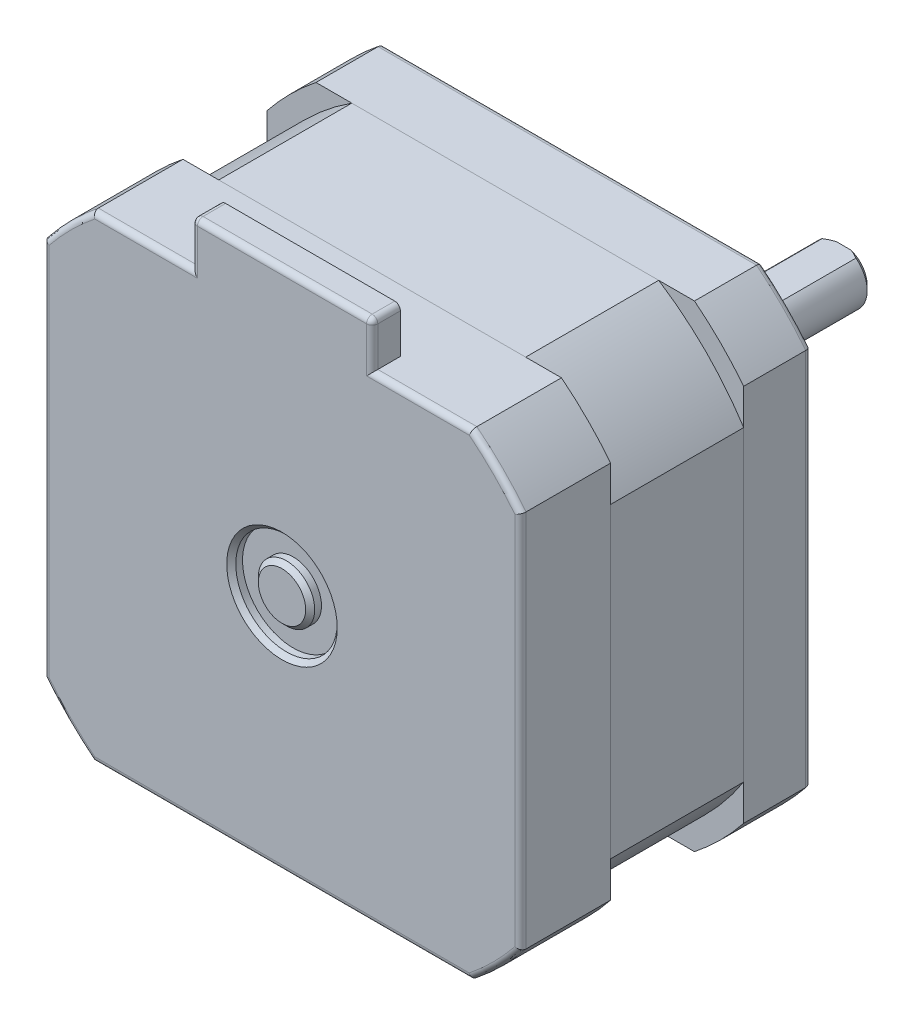
from build123d import *

# Parameters (mm, degrees)
BOSS_EXTRU_1_DEPTH           = 6
BOSS_EXTRU_2_DEPTH           = 11.8
BOSS_EXTRU_3_DEPTH           = 8
ESQUISSE4_W                  = 16
ESQUISSE4_H                  = 2.5
BOSS_EXTRU_4_DEPTH           = 4
ESQUISSE5_W                  = 2
ESQUISSE5_H                  = 6.5
ESQUISSE5_W_2                = 24
ESQUISSE5_H_2                = 2.5
CONG_1_R                     = 0.5
CONG_2_R                     = 0.5
CHANFREIN1_SIZE              = 0.4
CHANFREIN2_SIZE              = 0.4
ESQUISSE6_W                  = 15
ESQUISSE6_H                  = 0.5
ENL_V_MAT_EXTRU_1_DEPTH      = 22.1500001
ENL_V_MAT_EXTRU_1_DEPTH_BACK = 22.1500001
ESQUISSE7_R                  = 4.5
ESQUISSE7_R_2                = 2.5
ENL_V_MAT_EXTRU_2_DEPTH      = 1
CHANFREIN3_SIZE              = 0.4
TROU_TARAUD_M31_AT_2_COUNT   = 2
TROU_TARAUD_M31_AT_2_PITCH   = 31
TROU_TARAUD_M31_AT_3_COUNT   = 2
TROU_TARAUD_M31_AT_3_PITCH   = 43.840620434
TROU_TARAUD_M31_AT_4_COUNT   = 2
TROU_TARAUD_M31_AT_4_PITCH   = 31


with BuildPart() as part:
    # Esquisse1 → Boss.-Extru.1 (new body)
    with BuildSketch(Plane.XY):
        with BuildLine():
            Line((21.15, 16.783250579), (21.15, -16.783250579))
            ThreePointArc((21.15, -16.783250579), (19.091883092, -19.091883092), (16.783250579, -21.15))
            Line((16.783250579, -21.15), (-16.783250579, -21.15))
            ThreePointArc((-16.783250579, -21.15), (-19.091883092, -19.091883092), (-21.15, -16.783250579))
            Line((-21.15, -16.783250579), (-21.15, 16.783250579))
            ThreePointArc((-21.15, 16.783250579), (-19.091883092, 19.091883092), (-16.783250579, 21.15))
            Line((-16.783250579, 21.15), (16.783250579, 21.15))
            ThreePointArc((16.783250579, 21.15), (19.091883092, 19.091883092), (21.15, 16.783250579))
        make_face()
    extrude(amount=BOSS_EXTRU_1_DEPTH)

    # Congé2
    cong_2_edges = [part.edges().sort_by_distance(p)[0] for p in [
        (0, 21.15, 0),
        (19.091883092, 19.091883092, 0),
        (21.15, 0, 0),
        (19.091883092, -19.091883092, 0),
        (0, -21.15, 0),
        (-19.091883092, -19.091883092, 0),
        (-21.15, 0, 0),
        (-19.091883092, 19.091883092, 0),
    ]]
    fillet(cong_2_edges, radius=CONG_2_R)

    # Esquisse9 → Trou taraudé M31 (revolve, cut)
    with BuildSketch(Plane(origin=(15.5, -15.5, 0), x_dir=(0, 1, 0), z_dir=(1, 0, 0))):
        Polygon((0, 0), (0, 5.751075774), (1.25, 5), (1.25, 0), align=None)
    trou_taraud_m31 = revolve(axis=Axis((15.5, -15.5, -6.35), (0, 0, 1)), mode=Mode.SUBTRACT)

    # Trou taraudé M31 at 2: Trou taraudé M31 ×2
    with Locations(*[(0, i * TROU_TARAUD_M31_AT_2_PITCH, 0) for i in range(1, TROU_TARAUD_M31_AT_2_COUNT)]):
        add(trou_taraud_m31, mode=Mode.SUBTRACT)

    # Trou taraudé M31 at 3: Trou taraudé M31 ×2
    with Locations(*[Vector(-0.707106781, 0.707106781, 0) * (i * TROU_TARAUD_M31_AT_3_PITCH) for i in range(1, TROU_TARAUD_M31_AT_3_COUNT)]):
        add(trou_taraud_m31, mode=Mode.SUBTRACT)

    # Trou taraudé M31 at 4: Trou taraudé M31 ×2
    with Locations(*[(-i * TROU_TARAUD_M31_AT_4_PITCH, 0, 0) for i in range(1, TROU_TARAUD_M31_AT_4_COUNT)]):
        add(trou_taraud_m31, mode=Mode.SUBTRACT)


with BuildPart() as body_2:
    # Esquisse2 → Boss.-Extru.2 (new body)
    with BuildSketch(Plane.XY.offset(6)):
        with BuildLine():
            Line((-13.608820669, 21.15), (13.608820669, 21.15))
            ThreePointArc((13.608820669, 21.15), (17.783735547, 17.783735547), (21.15, 13.608820669))
            Line((21.15, 13.608820669), (21.15, -13.608820669))
            ThreePointArc((21.15, -13.608820669), (17.783735547, -17.783735547), (13.608820669, -21.15))
            Line((13.608820669, -21.15), (-13.608820669, -21.15))
            ThreePointArc((-13.608820669, -21.15), (-17.783735547, -17.783735547), (-21.15, -13.608820669))
            Line((-21.15, -13.608820669), (-21.15, 13.608820669))
            ThreePointArc((-21.15, 13.608820669), (-17.783735547, 17.783735547), (-13.608820669, 21.15))
        make_face()
    extrude(amount=BOSS_EXTRU_2_DEPTH)


with BuildPart() as body_3:
    # Esquisse3 → Boss.-Extru.3 (new body)
    with BuildSketch(Plane.XY.offset(17.8)):
        with BuildLine():
            Line((-16.783250579, -21.15), (16.783250579, -21.15))
            ThreePointArc((16.783250579, -21.15), (19.091883092, -19.091883092), (21.15, -16.783250579))
            Line((21.15, -16.783250579), (21.15, 16.783250579))
            ThreePointArc((21.15, 16.783250579), (19.091883092, 19.091883092), (16.783250579, 21.15))
            Line((16.783250579, 21.15), (-16.783250579, 21.15))
            ThreePointArc((-16.783250579, 21.15), (-19.091883092, 19.091883092), (-21.15, 16.783250579))
            Line((-21.15, 16.783250579), (-21.15, -16.783250579))
            ThreePointArc((-21.15, -16.783250579), (-19.091883092, -19.091883092), (-16.783250579, -21.15))
        make_face()
    extrude(amount=BOSS_EXTRU_3_DEPTH)

    # Esquisse4 → Boss.-Extru.4 (add)
    with BuildSketch(Plane(origin=(0, 21.15, 0), x_dir=(1, 0, 0), z_dir=(0, 1, 0))):
        with Locations((0, -24.55)):
            Rectangle(ESQUISSE4_W, ESQUISSE4_H)
    extrude(amount=BOSS_EXTRU_4_DEPTH)

    # Congé1
    cong_1_edges = [body_3.edges().sort_by_distance(p)[0] for p in [
        (19.091883092, -19.091883092, 25.8),
        (21.15, 0, 25.8),
        (19.091883092, 19.091883092, 25.8),
        (12.39162529, 21.15, 25.8),
        (-19.091883092, 19.091883092, 25.8),
        (-21.15, 0, 25.8),
        (-12.39162529, 21.15, 25.8),
        (8, 23.15, 25.8),
        (-8, 23.15, 25.8),
        (8, 25.15, 24.55),
        (-8, 25.15, 24.55),
        (0, 25.15, 25.8),
        (-19.091883092, -19.091883092, 25.8),
        (0, -21.15, 25.8),
    ]]
    fillet(cong_1_edges, radius=CONG_1_R)

    # Esquisse7 → Enlèv. mat.-Extru.2 (cut)
    with BuildSketch(Plane.XY.offset(25.8)):
        Circle(ESQUISSE7_R)
        Circle(ESQUISSE7_R_2, mode=Mode.SUBTRACT)
    extrude(amount=-ENL_V_MAT_EXTRU_2_DEPTH, mode=Mode.SUBTRACT)

    # Chanfrein3
    chanfrein3_edges = [body_3.edges().sort_by_distance(p)[0] for p in [
        (-4.5, 0, 25.8),
        (-2.5, 0, 25.8),
    ]]
    chamfer(chanfrein3_edges, length=CHANFREIN3_SIZE)


with BuildPart() as body_4:
    # Esquisse5 → Révolution1 (revolve)
    with BuildSketch(Plane(origin=(0, 0, 0), x_dir=(0, 0, -1), z_dir=(1, 0, 0))):
        with Locations((1, 7.75)):
            Rectangle(ESQUISSE5_W, ESQUISSE5_H)
        with Locations((12, 1.25)):
            Rectangle(ESQUISSE5_W_2, ESQUISSE5_H_2)
    revolve(axis=Axis((0, 0, 0), (0, 0, 1)))

    # Chanfrein1
    chanfrein1_edges = [body_4.edges().sort_by_distance(p)[0] for p in [
        (0, -2.5, -24),
    ]]
    chamfer(chanfrein1_edges, length=CHANFREIN1_SIZE)

    # Chanfrein2
    chanfrein2_edges = [body_4.edges().sort_by_distance(p)[0] for p in [
        (0, -11, -2),
        (0, -4.5, -2),
    ]]
    chamfer(chanfrein2_edges, length=CHANFREIN2_SIZE)

    # Esquisse6 → Enlèv. mat.-Extru.1 (cut, two sides)
    with BuildSketch(Plane(origin=(0, 0, 0), x_dir=(0, 0, -1), z_dir=(1, 0, 0))) as enl_v_mat_extru_1_sk:
        with Locations((16.5, 2.25)):
            Rectangle(ESQUISSE6_W, ESQUISSE6_H)
    extrude(amount=ENL_V_MAT_EXTRU_1_DEPTH, mode=Mode.SUBTRACT)
    extrude(enl_v_mat_extru_1_sk.sketch, amount=-ENL_V_MAT_EXTRU_1_DEPTH_BACK, mode=Mode.SUBTRACT)


solid = Compound([part.part, body_2.part, body_3.part, body_4.part])
